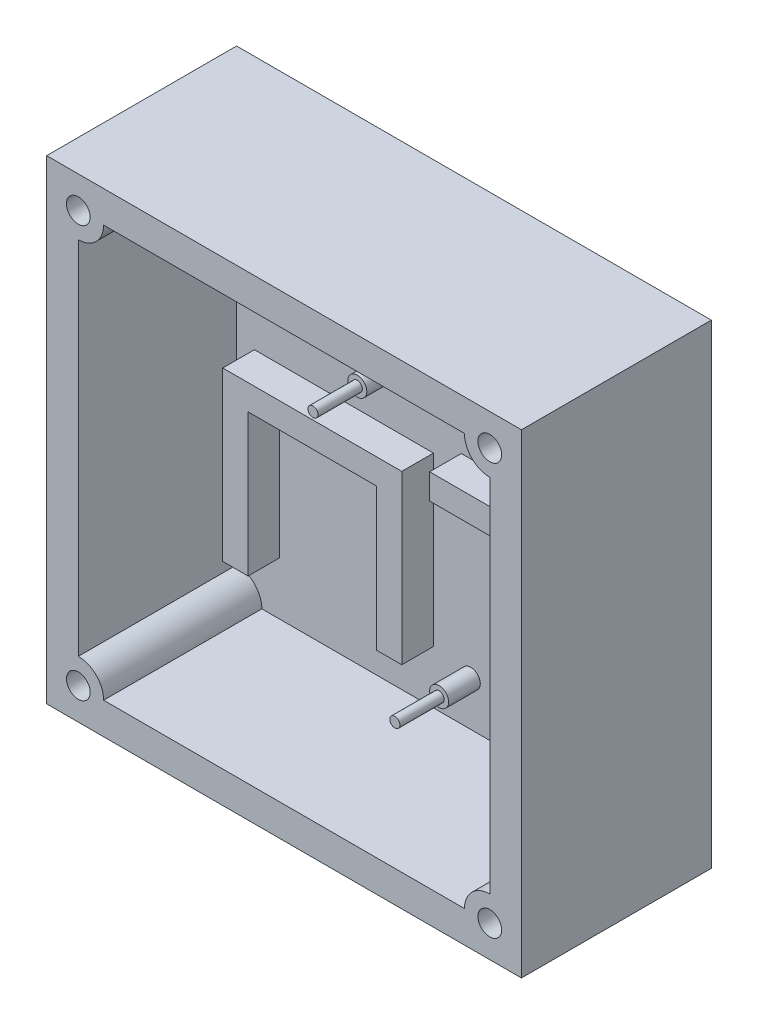
from build123d import *

# Parameters (mm, degrees)
SKETCH1_W           = 95.25
SKETCH1_H           = 95.25
BOSS_EXTRUDE1_DEPTH = 38.1
SHELL1_T            = -6.35
BOSS_EXTRUDE2_DEPTH = 31.75
SKETCH3_R           = 1.905
SKETCH3_R_2         = 1.016
BOSS_EXTRUDE3_DEPTH = 6.35
SKETCH4_R           = 1.016
BOSS_EXTRUDE4_DEPTH = 8.89
SKETCH5_R           = 1.905
SKETCH5_W           = 31.75
SKETCH5_H           = 5.08
BOSS_EXTRUDE5_DEPTH = 6.35
SKETCH7_R           = 1.016
BOSS_EXTRUDE6_DEPTH = 8.89
SKETCH8_R           = 2.38125
CUT_EXTRUDE1_DEPTH  = 8.89
BOSS_EXTRUDE7_DEPTH = 6.35


with BuildPart() as part:
    # Sketch1 → Boss-Extrude1 (new body)
    with BuildSketch(Plane.XY):
        Rectangle(SKETCH1_W, SKETCH1_H)
    extrude(amount=BOSS_EXTRUDE1_DEPTH)

    # Shell1
    shell1_openings = [part.faces().sort_by_distance(p)[0] for p in [
        (0, 0, 38.1),
    ]]
    offset(amount=SHELL1_T, openings=shell1_openings, kind=Kind.INTERSECTION)

    # Sketch2 → Boss-Extrude2 (add)
    with BuildSketch(Plane.XY.offset(38.1)):
        with BuildLine():
            Line((-41.275, 41.275), (-36.195, 41.275))
            ThreePointArc((-36.195, 41.275), (-37.682897552, 37.682897552), (-41.275, 36.195))
            Line((-41.275, 36.195), (-41.275, 41.275))
        make_face()
        with BuildLine():
            Line((36.195, 41.275), (41.275, 41.275))
            Line((41.275, 41.275), (41.275, 36.195))
            ThreePointArc((41.275, 36.195), (37.682897552, 37.682897552), (36.195, 41.275))
        make_face()
        with BuildLine():
            Line((41.275, -36.195), (41.275, -41.275))
            Line((41.275, -41.275), (36.195, -41.275))
            ThreePointArc((36.195, -41.275), (37.682897552, -37.682897552), (41.275, -36.195))
        make_face()
        with BuildLine():
            Line((-41.275, -36.195), (-41.275, -41.275))
            Line((-41.275, -41.275), (-36.195, -41.275))
            ThreePointArc((-36.195, -41.275), (-37.682897552, -37.682897552), (-41.275, -36.195))
        make_face()
    extrude(amount=-BOSS_EXTRUDE2_DEPTH)

    # Sketch3 → Boss-Extrude3 (add)
    with BuildSketch(Plane.XY.offset(6.35)):
        with Locations((35.015710728, 31.115)):
            Circle(SKETCH3_R)
        with Locations((-10.704289272, 31.115)):
            Circle(SKETCH3_R_2)
        with Locations((-10.704289272, 13.335)):
            Circle(SKETCH3_R)
        with Locations((35.015710728, 13.335)):
            Circle(SKETCH3_R)
    extrude(amount=BOSS_EXTRUDE3_DEPTH)

    # Sketch4 → Boss-Extrude4 (add)
    with BuildSketch(Plane.XY.offset(12.7)):
        with Locations((-10.704289272, 31.115)):
            Circle(SKETCH4_R)
        with Locations((-10.704289272, 13.335)):
            Circle(SKETCH4_R)
        with Locations((35.015710728, 31.115)):
            Circle(SKETCH4_R)
        with Locations((35.015710728, 13.335)):
            Circle(SKETCH4_R)
    extrude(amount=BOSS_EXTRUDE4_DEPTH)

    # Sketch5 → Boss-Extrude5 (add)
    with BuildSketch(Plane.XY.offset(6.35)):
        with Locations((5.715, -32.385)):
            Circle(SKETCH5_R)
        with Locations((33.655, -32.385)):
            Circle(SKETCH5_R)
        with Locations((19.685, 3.175)):
            Rectangle(SKETCH5_W, SKETCH5_H)
    extrude(amount=BOSS_EXTRUDE5_DEPTH)

    # Sketch7 → Boss-Extrude6 (add)
    with BuildSketch(Plane.XY.offset(12.7)):
        with Locations((5.715, -32.385)):
            Circle(SKETCH7_R)
        with Locations((33.655, -32.385)):
            Circle(SKETCH7_R)
    extrude(amount=BOSS_EXTRUDE6_DEPTH)

    # Sketch8 → Cut-Extrude1 (cut)
    with BuildSketch(Plane.XY.offset(38.1)):
        with Locations((-41.275, 41.275)):
            Circle(SKETCH8_R)
        with Locations((41.275, 41.275)):
            Circle(SKETCH8_R)
        with Locations((41.275, -41.275)):
            Circle(SKETCH8_R)
        with Locations((-41.275, -41.275)):
            Circle(SKETCH8_R)
    extrude(amount=-CUT_EXTRUDE1_DEPTH, mode=Mode.SUBTRACT)

    # Sketch10 → Boss-Extrude7 (add)
    with BuildSketch(Plane.XY.offset(6.35)):
        Polygon((-37.696932409, -30.607), (-37.696932409, 2.9972), (-1.781332409, 2.9972), (-1.781332409, -30.607), (-6.861332409, -30.607), (-6.861332409, -2.0828), (-32.616932409, -2.0828), (-32.616932409, -30.607), align=None)
    extrude(amount=BOSS_EXTRUDE7_DEPTH)


solid = part.part
